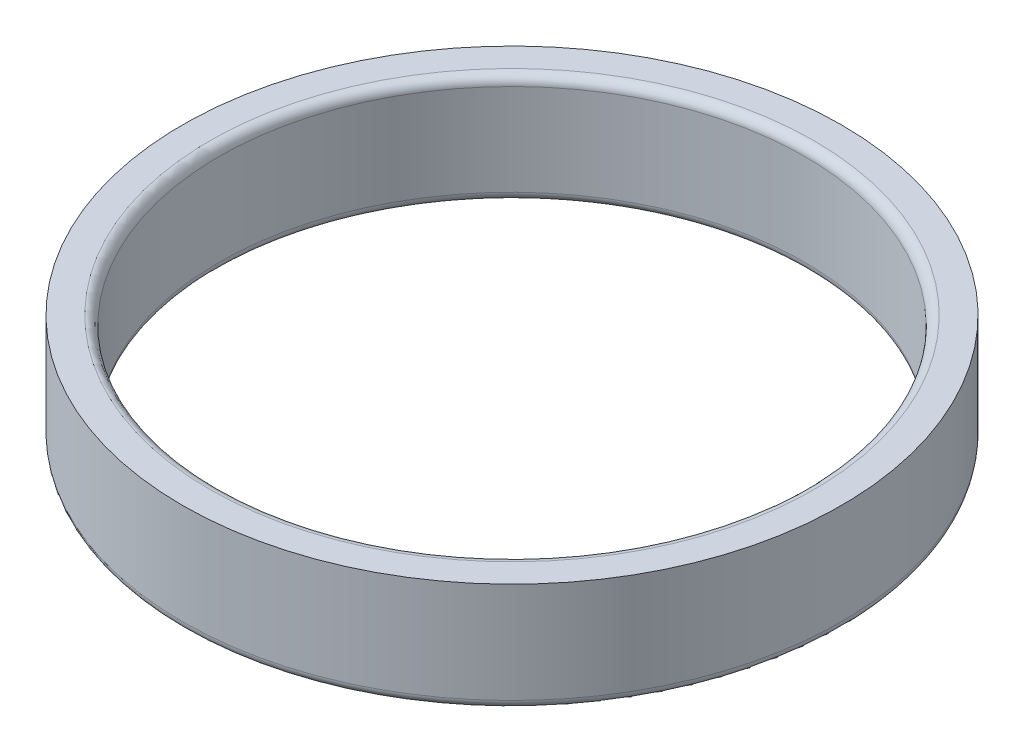
from build123d import *

# Parameters (mm, degrees)
SKETCH_1_R      = 9
SKETCH_1_R_2    = 8
EXTRUDE_1_DEPTH = 3
FILLET_1_R      = 0.25


with BuildPart() as part:
    # 草图1 → 凸台-拉伸1 (new body)
    with BuildSketch(Plane(origin=(0, 0, 0), x_dir=(1, 0, 0), z_dir=(0, 1, 0))):
        Circle(SKETCH_1_R)
        Circle(SKETCH_1_R_2, mode=Mode.SUBTRACT)
    extrude(amount=EXTRUDE_1_DEPTH)

    # 圆角1
    fillet_1_edges = [part.edges().sort_by_distance(p)[0] for p in [
        (-9, 0, 0),
        (-8, 0, 0),
        (-8, 3, 0),
    ]]
    fillet(fillet_1_edges, radius=FILLET_1_R)


solid = part.part
